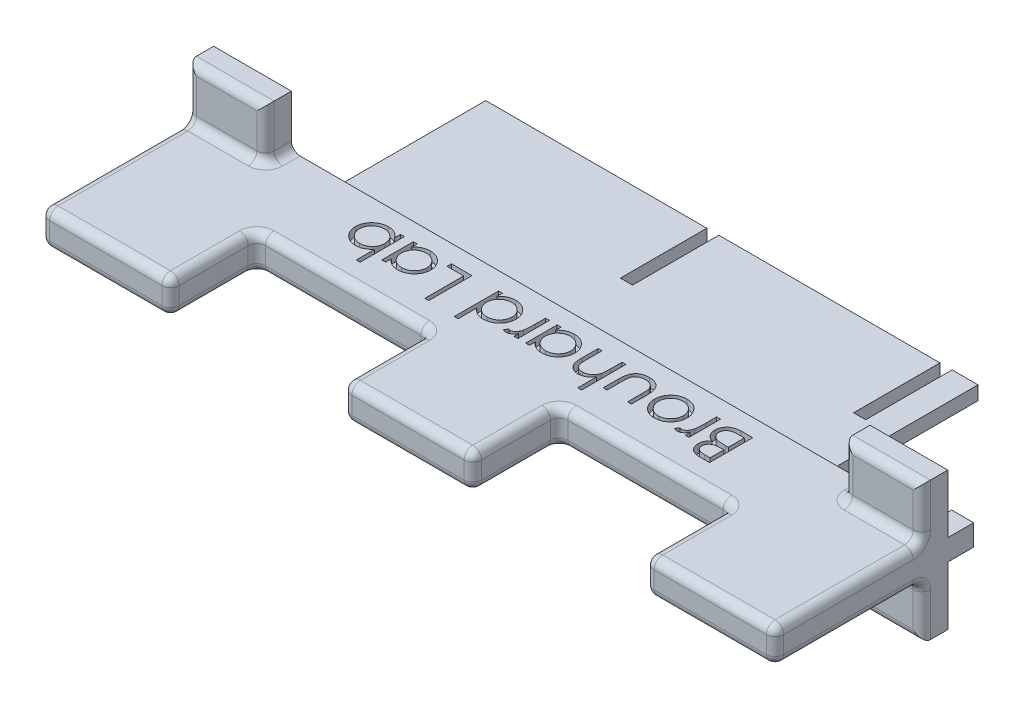
from build123d import *

# Parameters (mm, degrees)
SKETCH1_W           = 85
SKETCH1_H           = 4
BOSS_EXTRUDE1_DEPTH = 10
SKETCH2_W           = 15
SKETCH2_H           = 4
BOSS_EXTRUDE2_DEPTH = 10
SKETCH3_W           = 2.55
SKETCH3_H           = 2.45
BOSS_EXTRUDE3_DEPTH = 3
SKETCH4_W           = 57
SKETCH4_H           = 1.6
BOSS_EXTRUDE4_DEPTH = 7.5
SKETCH6_W           = 9
SKETCH6_H           = 6
BOSS_EXTRUDE6_DEPTH = 3
FILLET1_R           = 1
CUT_EXTRUDE1_DEPTH  = 1
SKETCH5_W           = 25.6
SKETCH5_H           = 1.6
SKETCH5_W_2         = 3
BOSS_EXTRUDE5_DEPTH = 10


with BuildPart() as part:
    # Sketch1 → Boss-Extrude1 (new body)
    with BuildSketch(Plane.XY):
        Rectangle(SKETCH1_W, SKETCH1_H)
    extrude(amount=BOSS_EXTRUDE1_DEPTH)

    # Sketch2 → Boss-Extrude2 (add)
    with BuildSketch(Plane.XY.offset(10)):
        with Locations((-35, 0)):
            Rectangle(SKETCH2_W, SKETCH2_H)
        with Locations((35, 0)):
            Rectangle(SKETCH2_W, SKETCH2_H)
        Rectangle(SKETCH2_W, SKETCH2_H)
    extrude(amount=BOSS_EXTRUDE2_DEPTH)

    # Sketch3 → Boss-Extrude3 (add)
    with BuildSketch(Plane(origin=(0, 0, 0), x_dir=(-1, 0, 0), z_dir=(0, 0, -1))):
        with Locations((-41.225, 0)):
            Rectangle(SKETCH3_W, SKETCH3_H)
        with Locations((41.225, 0)):
            Rectangle(SKETCH3_W, SKETCH3_H)
    extrude(amount=BOSS_EXTRUDE3_DEPTH)

    # Sketch4 → Boss-Extrude4 (add)
    with BuildSketch(Plane(origin=(0, 0, 0), x_dir=(-1, 0, 0), z_dir=(0, 0, -1))):
        Rectangle(SKETCH4_W, SKETCH4_H)
    extrude(amount=BOSS_EXTRUDE4_DEPTH)

    # Sketch6 → Boss-Extrude6 (add)
    with BuildSketch(Plane(origin=(0, 0, 0), x_dir=(-1, 0, 0), z_dir=(0, 0, -1))):
        with Locations((38, -5)):
            Rectangle(SKETCH6_W, SKETCH6_H)
        with Locations((38, 5)):
            Rectangle(SKETCH6_W, SKETCH6_H)
        with Locations((-38, -5)):
            Rectangle(SKETCH6_W, SKETCH6_H)
        with Locations((-38, 5)):
            Rectangle(SKETCH6_W, SKETCH6_H)
    extrude(amount=-BOSS_EXTRUDE6_DEPTH)

    # Fillet1
    fillet1_edges = [part.edges().sort_by_distance(p)[0] for p in [
        (-42.5, 5, 3),
        (-38, 2, 3),
        (-33.5, 5, 3),
        (-33.5, 2, 1.5),
        (-38, 8, 3),
        (42.5, -5, 3),
        (38, -2, 3),
        (33.5, -5, 3),
        (33.5, -2, 1.5),
        (38, -8, 3),
        (42.5, 5, 3),
        (38, 8, 3),
        (33.5, 5, 3),
        (38, 2, 3),
        (33.5, 2, 1.5),
        (-17.5, -2, 10),
        (-27.5, 0, 10),
        (-27.5, -2, 15),
        (-27.5, 2, 15),
        (-42.5, 0, 20),
        (-35, -2, 20),
        (-27.5, 0, 20),
        (-35, 2, 20),
        (17.5, 2, 10),
        (27.5, 0, 10),
        (27.5, 2, 15),
        (27.5, -2, 15),
        (42.5, 0, 20),
        (35, 2, 20),
        (27.5, 0, 20),
        (35, -2, 20),
        (17.5, -2, 10),
        (-17.5, 2, 10),
        (7.5, 0, 10),
        (7.5, -2, 15),
        (7.5, 2, 15),
        (-7.5, 0, 10),
        (-7.5, 2, 15),
        (-7.5, -2, 15),
        (7.5, 0, 20),
        (0, 2, 20),
        (-7.5, 0, 20),
        (0, -2, 20),
        (42.5, -2, 11.5),
        (-42.5, -2, 11.5),
        (-42.5, 2, 11.5),
        (42.5, 2, 11.5),
        (-42.5, -5, 3),
        (-38, -8, 3),
        (-33.5, -5, 3),
        (-38, -2, 3),
        (-33.5, -2, 1.5),
    ]]
    fillet(fillet1_edges, radius=FILLET1_R)

    # Sketch8 → Cut-Extrude1 (cut)
    with BuildSketch(Plane(origin=(0, 2, 0), x_dir=(1, 0, 0), z_dir=(0, 1, 0))):
        with BuildLine():
            Line((21.955128205, -7.045024133), (20.979567308, -7.045024133))
            add(Edge.make_bspline(
                [(20.979567308, -7.045024133), (20.931811586, -7.044777014), (20.839249111, -7.044298035), (20.704660144, -7.036696988), (20.578554958, -7.026592114), (20.461156398, -7.009641733), (20.351700568, -6.992066423), (20.251298675, -6.966270076), (20.159109728, -6.937777071), (20.048409672, -6.893936716), (19.92280529, -6.825852091), (19.787804083, -6.724876123), (19.670452795, -6.603814091), (19.570669416, -6.465854357), (19.490591132, -6.314083016), (19.43339094, -6.151765477), (19.396643358, -5.981632539), (19.392911608, -5.864990679), (19.391025641, -5.806041761)],
                knots=[0, 0, 0, 0, 0.000143243, 0.000277641, 0.000404323, 0.000522601, 0.000633422, 0.000736665, 0.000833282, 0.000922745, 0.001093491, 0.001260157, 0.001426607, 0.001597303, 0.001769346, 0.001939468, 0.002112331, 0.002288957, 0.002288957, 0.002288957, 0.002288957], degree=3))
            add(Edge.make_bspline(
                [(19.391025641, -5.806041761), (19.392566125, -5.750816773), (19.395593321, -5.642294463), (19.425166581, -5.484100137), (19.4698067, -5.333038737), (19.534225102, -5.190566035), (19.616363978, -5.057933935), (19.716298264, -4.937404803), (19.834792937, -4.831345021), (19.923759393, -4.772321243), (19.968950321, -4.742339838)],
                knots=[0, 0, 0, 0, 0.00016551, 0.000325243, 0.000481139, 0.000637145, 0.000792791, 0.000947835, 0.001105294, 0.001267844, 0.001267844, 0.001267844, 0.001267844], degree=3))
            add(Edge.make_bspline(
                [(19.968950321, -4.742339838), (19.912145679, -4.720542475), (19.803464327, -4.678838718), (19.653711211, -4.604821394), (19.524645211, -4.524933301), (19.41460302, -4.438588883), (19.32239544, -4.34296875), (19.240253224, -4.240591123), (19.170541651, -4.127890536), (19.111062126, -4.007309158), (19.063944891, -3.879485542), (19.031238978, -3.745375962), (19.010496783, -3.606499394), (19.007784363, -3.512111636), (19.006410256, -3.464294967)],
                knots=[0, 0, 0, 0, 0.000182459, 0.00034909, 0.000500276, 0.000637148, 0.000767471, 0.00089793, 0.001030217, 0.001164151, 0.001300726, 0.001437979, 0.001577644, 0.001721044, 0.001721044, 0.001721044, 0.001721044], degree=3))
            add(Edge.make_bspline(
                [(19.006410256, -3.464294967), (19.007805885, -3.41548523), (19.010551822, -3.319450707), (19.030807012, -3.178370784), (19.065112767, -3.043553694), (19.112331393, -2.914102037), (19.173883248, -2.790773975), (19.248244287, -2.672600284), (19.337493216, -2.561332318), (19.437996289, -2.45535544), (19.550128803, -2.358444164), (19.673690061, -2.2751618), (19.805513315, -2.203227398), (19.947403728, -2.145396174), (20.098354491, -2.100124903), (20.258400966, -2.068824422), (20.427452272, -2.047649449), (20.543467886, -2.045914087), (20.602964744, -2.045024133)],
                knots=[0, 0, 0, 0, 0.000146402, 0.00028805, 0.000426518, 0.000563092, 0.000700608, 0.000839267, 0.000981145, 0.001127794, 0.001276955, 0.001424748, 0.00157399, 0.001726698, 0.001883553, 0.002046002, 0.002215459, 0.002393845, 0.002393845, 0.002393845, 0.002393845], degree=3))
            Line((20.602964744, -2.045024133), (21.955128205, -2.045024133))
            Line((21.955128205, -2.045024133), (21.955128205, -7.045024133))
        make_face()
        with BuildLine():
            Line((21.506410256, -6.53220362), (21.506410256, -4.929639518))
            Line((21.506410256, -4.929639518), (21.204927885, -4.929639518))
            add(Edge.make_bspline(
                [(21.204927885, -4.929639518), (21.16085778, -4.930206082), (21.075705357, -4.9313008), (20.952063514, -4.934535484), (20.837581625, -4.943196106), (20.731865233, -4.952356158), (20.635622811, -4.966460704), (20.548532434, -4.983720889), (20.469810894, -5.00181496), (20.379071632, -5.032675643), (20.276157749, -5.077807077), (20.16721677, -5.149562501), (20.069164992, -5.232639769), (19.988277934, -5.331182392), (19.920936523, -5.437599512), (19.875598165, -5.552684686), (19.843986577, -5.672472047), (19.841172407, -5.755083607), (19.83974359, -5.797027338)],
                knots=[0, 0, 0, 0, 0.000132227, 0.000255489, 0.000370952, 0.000476596, 0.000573767, 0.000662554, 0.000742964, 0.000815812, 0.000949851, 0.001078759, 0.001205868, 0.001333854, 0.001459773, 0.001581973, 0.001703679, 0.001829203, 0.001829203, 0.001829203, 0.001829203], degree=3))
            add(Edge.make_bspline(
                [(19.83974359, -5.797027338), (19.840440447, -5.824795004), (19.841807408, -5.879264312), (19.85469429, -5.958622966), (19.872478035, -6.034141042), (19.901807859, -6.103782707), (19.936556119, -6.169993364), (19.98109509, -6.230681546), (20.03245262, -6.287491301), (20.092329064, -6.338899898), (20.160479658, -6.385396007), (20.239063252, -6.424101797), (20.325943351, -6.458499162), (20.422931675, -6.48457317), (20.528096305, -6.507209559), (20.643041681, -6.521483941), (20.767075062, -6.530654029), (20.853013063, -6.531675569), (20.897435897, -6.53220362)],
                knots=[0, 0, 0, 0, 8.3229e-05, 0.000163264, 0.000240757, 0.000315341, 0.000389283, 0.000464617, 0.000540481, 0.000618594, 0.000700823, 0.000787274, 0.000880832, 0.000980716, 0.001088168, 0.001203335, 0.00132786, 0.001461107, 0.001461107, 0.001461107, 0.001461107], degree=3))
            Line((20.897435897, -6.53220362), (21.506410256, -6.53220362))
        make_face(mode=Mode.SUBTRACT)
        with BuildLine():
            Line((21.506410256, -4.416819005), (21.506410256, -2.557844646))
            Line((21.506410256, -2.557844646), (20.867387821, -2.557844646))
            add(Edge.make_bspline(
                [(20.867387821, -2.557844646), (20.82165107, -2.558445571), (20.733499514, -2.559603775), (20.606126985, -2.562352033), (20.48869926, -2.57254806), (20.380238634, -2.582323383), (20.281246941, -2.598293401), (20.190761319, -2.61375789), (20.110848501, -2.63651465), (20.017345889, -2.667828353), (19.912764158, -2.717871803), (19.798555972, -2.791464981), (19.697962318, -2.881106895), (19.612615651, -2.984324471), (19.541653639, -3.095395221), (19.492561941, -3.214537751), (19.460753316, -3.337772506), (19.457007017, -3.422035912), (19.455128205, -3.464294967)],
                knots=[0, 0, 0, 0, 0.000137234, 0.000264501, 0.000382034, 0.000490767, 0.000591058, 0.000682796, 0.000765899, 0.000840017, 0.000978463, 0.001112367, 0.001246451, 0.001380849, 0.001513136, 0.001640186, 0.001766022, 0.001892621, 0.001892621, 0.001892621, 0.001892621], degree=3))
            add(Edge.make_bspline(
                [(19.455128205, -3.464294967), (19.455511728, -3.490717987), (19.456272588, -3.543137822), (19.468232548, -3.620102651), (19.484829912, -3.695025725), (19.509289766, -3.766889341), (19.538879538, -3.836930979), (19.577915987, -3.902871611), (19.621948812, -3.967518228), (19.690148998, -4.050208407), (19.790699472, -4.144331407), (19.933635519, -4.235332182), (20.095250073, -4.309910154), (20.212743455, -4.341437989), (20.2734375, -4.357724454)],
                knots=[0, 0, 0, 0, 7.9184e-05, 0.00015709, 0.000233139, 0.000309156, 0.000384516, 0.000460796, 0.000538586, 0.000618995, 0.000781989, 0.000949233, 0.001125381, 0.001313608, 0.001313608, 0.001313608, 0.001313608], degree=3))
            add(Edge.make_bspline(
                [(20.2734375, -4.357724454), (20.297764757, -4.36266062), (20.350511268, -4.373363246), (20.436522534, -4.384653585), (20.535045896, -4.394781387), (20.645660247, -4.402076233), (20.768805516, -4.409907124), (20.904442139, -4.412844185), (21.052666008, -4.416429024), (21.15551238, -4.416685686), (21.208934295, -4.416819005)],
                knots=[0, 0, 0, 0, 7.4449e-05, 0.000161422, 0.000260089, 0.000371555, 0.000493951, 0.000630228, 0.000778496, 0.000938755, 0.000938755, 0.000938755, 0.000938755], degree=3))
            Line((21.208934295, -4.416819005), (21.506410256, -4.416819005))
        make_face(mode=Mode.SUBTRACT)
        with BuildLine():
            Line((18.237179487, -5.698870287), (17.788461538, -5.698870287))
            Line((17.788461538, -5.698870287), (17.788461538, -5.16100971))
            add(Edge.make_bspline(
                [(17.788461538, -5.16100971), (17.755359908, -5.211117117), (17.692053298, -5.306947144), (17.586273377, -5.43343718), (17.479111393, -5.53983342), (17.366921794, -5.622588498), (17.252557594, -5.685650706), (17.136357118, -5.730343447), (17.017481778, -5.757585182), (16.937237879, -5.761174556), (16.897035256, -5.762972851)],
                knots=[0, 0, 0, 0, 0.000180032, 0.00034431, 0.000493764, 0.000631989, 0.000761087, 0.000884414, 0.00100446, 0.00112499, 0.00112499, 0.00112499, 0.00112499], degree=3))
            add(Edge.make_bspline(
                [(16.897035256, -5.762972851), (16.865844687, -5.761310147), (16.801992924, -5.757906343), (16.705041331, -5.732794344), (16.604739598, -5.694222955), (16.540012887, -5.657063647), (16.506410256, -5.637772531)],
                knots=[0, 0, 0, 0, 9.3493e-05, 0.000191394, 0.000298902, 0.000414971, 0.000414971, 0.000414971, 0.000414971], degree=3))
            Line((16.506410256, -5.637772531), (16.752804487, -5.249150736))
            add(Edge.make_bspline(
                [(16.752804487, -5.249150736), (16.774388803, -5.258779687), (16.815359967, -5.277057281), (16.875295061, -5.298688724), (16.930554114, -5.311425747), (16.965759197, -5.313355343), (16.982171474, -5.314254902)],
                knots=[0, 0, 0, 0, 7.0888e-05, 0.000134558, 0.000190943, 0.000240184, 0.000240184, 0.000240184, 0.000240184], degree=3))
            add(Edge.make_bspline(
                [(16.982171474, -5.314254902), (17.018552318, -5.311962095), (17.092095887, -5.307327204), (17.199553418, -5.267726819), (17.305221395, -5.20820996), (17.387285817, -5.138004944), (17.451536641, -5.071852679), (17.497773588, -5.013639038), (17.539299542, -4.947803919), (17.579572406, -4.876841023), (17.616991286, -4.798984205), (17.65042989, -4.714102186), (17.681701622, -4.622897124), (17.699312387, -4.559480067), (17.708333333, -4.526995287)],
                knots=[0, 0, 0, 0, 0.000108839, 0.000220017, 0.000339778, 0.000471355, 0.000542193, 0.000616339, 0.000693851, 0.000775474, 0.000861039, 0.000952734, 0.001049023, 0.001150145, 0.001150145, 0.001150145, 0.001150145], degree=3))
            add(Edge.make_bspline(
                [(17.708333333, -4.526995287), (17.715105579, -4.4980295), (17.73018081, -4.433550753), (17.744447085, -4.325868753), (17.75911049, -4.198727857), (17.769124119, -4.051980366), (17.778583328, -3.885062178), (17.783808984, -3.698693379), (17.788295276, -3.492361731), (17.78840435, -3.348446216), (17.788461538, -3.272988877)],
                knots=[0, 0, 0, 0, 8.9193e-05, 0.000198547, 0.000325526, 0.000473173, 0.000639683, 0.000827079, 0.001032447, 0.001258811, 0.001258811, 0.001258811, 0.001258811], degree=3))
            Line((17.788461538, -3.272988877), (17.788461538, -2.045024133))
            Line((17.788461538, -2.045024133), (18.237179487, -2.045024133))
            Line((18.237179487, -2.045024133), (18.237179487, -5.698870287))
        make_face()
        with BuildLine():
            add(Edge.make_bspline(
                [(14.29286859, -5.762972851), (14.224307927, -5.761517291), (14.089877222, -5.758663293), (13.893032913, -5.728009819), (13.705327588, -5.681525783), (13.525956048, -5.616093456), (13.356402056, -5.530243686), (13.195151776, -5.426425769), (13.042528278, -5.303937317), (12.951070622, -5.209132095), (12.904647436, -5.16100971)],
                knots=[0, 0, 0, 0, 0.000205526, 0.000402987, 0.000596112, 0.000784972, 0.000974447, 0.001165038, 0.001359476, 0.001559909, 0.001559909, 0.001559909, 0.001559909], degree=3))
            add(Edge.make_bspline(
                [(12.904647436, -5.16100971), (12.864673216, -5.11498973), (12.785498387, -5.023840384), (12.683975931, -4.876046652), (12.59651656, -4.722989365), (12.526426616, -4.562636041), (12.471162296, -4.396386511), (12.431925587, -4.223669352), (12.408587109, -4.044865999), (12.405440013, -3.923431945), (12.403846154, -3.861931185)],
                knots=[0, 0, 0, 0, 0.000182745, 0.000361954, 0.000536876, 0.000710881, 0.000886036, 0.001061708, 0.001241475, 0.001425944, 0.001425944, 0.001425944, 0.001425944], degree=3))
            add(Edge.make_bspline(
                [(12.403846154, -3.861931185), (12.405248064, -3.800073959), (12.408018305, -3.677841197), (12.434223472, -3.497813533), (12.474982163, -3.323249495), (12.533313369, -3.154879952), (12.608110636, -2.992190127), (12.699383171, -2.835891045), (12.807770716, -2.685672654), (12.930635425, -2.542816985), (13.066416897, -2.411135675), (13.21375075, -2.296436369), (13.369848434, -2.197755629), (13.536840837, -2.119375683), (13.712350874, -2.056195988), (13.8974949, -2.012629522), (14.09210775, -1.986052796), (14.225006973, -1.982656037), (14.29286859, -1.980921569)],
                knots=[0, 0, 0, 0, 0.00018547, 0.000366497, 0.000544574, 0.000722589, 0.000900065, 0.001080956, 0.001264689, 0.001455025, 0.001645575, 0.001831106, 0.002014249, 0.002198383, 0.002383395, 0.002572886, 0.002767942, 0.002971467, 0.002971467, 0.002971467, 0.002971467], degree=3))
            add(Edge.make_bspline(
                [(14.29286859, -1.980921569), (14.361059424, -1.982670388), (14.494614618, -1.986095539), (14.689960267, -2.012431829), (14.875883807, -2.056661478), (15.052224048, -2.118593533), (15.219215773, -2.198399418), (15.37588985, -2.296052412), (15.523293198, -2.411193757), (15.65911724, -2.542801247), (15.781970535, -2.685676709), (15.890361026, -2.835889993), (15.981632796, -2.992190401), (16.056430263, -3.154879879), (16.114761415, -3.323249515), (16.155520121, -3.497813528), (16.181725284, -3.677841198), (16.184495525, -3.80007396), (16.185897436, -3.861931185)],
                knots=[0, 0, 0, 0, 0.000204526, 0.000400574, 0.000590065, 0.000776965, 0.000960195, 0.001144188, 0.00132972, 0.001520269, 0.001710605, 0.001894339, 0.00207523, 0.002252706, 0.002430721, 0.002608798, 0.002789825, 0.002975294, 0.002975294, 0.002975294, 0.002975294], degree=3))
            add(Edge.make_bspline(
                [(16.185897436, -3.861931185), (16.184296519, -3.923099043), (16.18112698, -4.044200892), (16.157756652, -4.22264832), (16.118946868, -4.394836864), (16.062916427, -4.560178538), (15.992956591, -4.720146456), (15.90637746, -4.873764934), (15.803872945, -5.02091287), (15.725005709, -5.111941341), (15.685096154, -5.158004902)],
                knots=[0, 0, 0, 0, 0.000183468, 0.000363236, 0.000538908, 0.000712162, 0.000886167, 0.001061962, 0.001240348, 0.001423094, 0.001423094, 0.001423094, 0.001423094], degree=3))
            add(Edge.make_bspline(
                [(15.685096154, -5.158004902), (15.638739114, -5.20653651), (15.547569839, -5.301982456), (15.394241809, -5.424229232), (15.233685171, -5.529446865), (15.063037498, -5.615253429), (14.883167202, -5.681407061), (14.694066814, -5.728226774), (14.496506031, -5.758527704), (14.361424213, -5.761476369), (14.29286859, -5.762972851)],
                knots=[0, 0, 0, 0, 0.00020114, 0.000395577, 0.000586713, 0.000776188, 0.000967274, 0.001160399, 0.001359841, 0.001565367, 0.001565367, 0.001565367, 0.001565367], degree=3))
        make_face()
        with BuildLine():
            add(Edge.make_bspline(
                [(14.294871795, -5.314254902), (14.343354042, -5.31287684), (14.439066976, -5.310156289), (14.579952881, -5.289466071), (14.715578773, -5.256679949), (14.84621924, -5.210117374), (14.971369132, -5.149920796), (15.091165691, -5.076401027), (15.205288814, -4.989167289), (15.312855022, -4.88995037), (15.412753003, -4.782192755), (15.499001382, -4.666286529), (15.572889716, -4.545452386), (15.633262525, -4.419007361), (15.679580189, -4.286604065), (15.712397714, -4.149000046), (15.733127199, -4.005785755), (15.735814091, -3.908409845), (15.737179487, -3.858926377)],
                knots=[0, 0, 0, 0, 0.000145402, 0.00028705, 0.000426247, 0.000563423, 0.000702299, 0.000842129, 0.000984361, 0.00113252, 0.001280679, 0.00142451, 0.001565195, 0.001704975, 0.001844039, 0.001985183, 0.002128814, 0.002277217, 0.002277217, 0.002277217, 0.002277217], degree=3))
            add(Edge.make_bspline(
                [(15.737179487, -3.858926377), (15.734890082, -3.794992084), (15.730346041, -3.668094469), (15.693206633, -3.48126298), (15.631516344, -3.301562306), (15.546449569, -3.131156088), (15.441687276, -2.973216762), (15.31918926, -2.831196974), (15.177261944, -2.710573578), (15.020738225, -2.609127271), (14.851836243, -2.5292384), (14.673387712, -2.471947456), (14.487017459, -2.435206285), (14.359480893, -2.431511347), (14.294871795, -2.429639518)],
                knots=[0, 0, 0, 0, 0.000191683, 0.000380455, 0.000568919, 0.000760186, 0.000950198, 0.001136194, 0.00132088, 0.001507019, 0.001694298, 0.001879594, 0.002068178, 0.002261801, 0.002261801, 0.002261801, 0.002261801], degree=3))
            add(Edge.make_bspline(
                [(14.294871795, -2.429639518), (14.23025898, -2.431500504), (14.102715078, -2.435174039), (13.916085515, -2.472133599), (13.737147914, -2.528989279), (13.568070317, -2.609217501), (13.411475317, -2.710190138), (13.270561459, -2.831884154), (13.147008507, -2.972843418), (13.04214248, -3.130946672), (12.958446366, -3.301827223), (12.896465966, -3.481229869), (12.859415628, -3.668102902), (12.854859565, -3.794994909), (12.852564103, -3.858926377)],
                knots=[0, 0, 0, 0, 0.000193623, 0.000382206, 0.000568456, 0.000755734, 0.000941873, 0.001125801, 0.001312456, 0.001502468, 0.001693291, 0.001881755, 0.002070527, 0.00226221, 0.00226221, 0.00226221, 0.00226221], degree=3))
            add(Edge.make_bspline(
                [(12.852564103, -3.858926377), (12.85391927, -3.908413822), (12.856586033, -4.00579756), (12.877461924, -4.148954918), (12.909764333, -4.286878115), (12.958078967, -4.418473367), (13.016348399, -4.546067931), (13.092028067, -4.665924648), (13.177874936, -4.782266279), (13.277956043, -4.889885455), (13.385510177, -4.98952979), (13.500490643, -5.076083255), (13.620342842, -5.149962779), (13.745532283, -5.210124787), (13.875877117, -5.256500729), (14.011091241, -5.289608892), (14.151353237, -5.310080851), (14.246726302, -5.312854653), (14.294871795, -5.314254902)],
                knots=[0, 0, 0, 0, 0.000148403, 0.000292034, 0.000433178, 0.000572578, 0.00071193, 0.000853138, 0.000996969, 0.001145128, 0.001293287, 0.001436317, 0.001576147, 0.001715023, 0.001852199, 0.001990424, 0.002132072, 0.002276473, 0.002276473, 0.002276473, 0.002276473], degree=3))
        make_face(mode=Mode.SUBTRACT)
        with BuildLine():
            Line((11.570512821, -5.698870287), (11.121794872, -5.698870287))
            Line((11.121794872, -5.698870287), (11.121794872, -4.004158749))
            add(Edge.make_bspline(
                [(11.121794872, -4.004158749), (11.121592151, -3.954411964), (11.121204354, -3.859248695), (11.118574439, -3.722312714), (11.112388591, -3.597431696), (11.104654555, -3.484533501), (11.094708647, -3.383637227), (11.082875275, -3.295095289), (11.069648958, -3.217903597), (11.056702224, -3.171413089), (11.05068109, -3.149791761)],
                knots=[0, 0, 0, 0, 0.000149242, 0.000285493, 0.000410838, 0.000524302, 0.000624962, 0.000714911, 0.000792314, 0.000859608, 0.000859608, 0.000859608, 0.000859608], degree=3))
            add(Edge.make_bspline(
                [(11.05068109, -3.149791761), (11.041021805, -3.122616307), (11.02190405, -3.06883037), (10.987228565, -2.991130691), (10.944327515, -2.919170094), (10.897397624, -2.850149082), (10.843207537, -2.786203671), (10.78254961, -2.72691621), (10.716500508, -2.671595092), (10.619751651, -2.6048734), (10.487494763, -2.534263345), (10.314242396, -2.472488378), (10.126045943, -2.436112097), (9.995820794, -2.431836921), (9.928886218, -2.429639518)],
                knots=[0, 0, 0, 0, 8.6516e-05, 0.000171232, 0.000254721, 0.000337515, 0.000421387, 0.00050567, 0.000591721, 0.00067952, 0.000857864, 0.001039709, 0.001229465, 0.001430146, 0.001430146, 0.001430146, 0.001430146], degree=3))
            add(Edge.make_bspline(
                [(9.928886218, -2.429639518), (9.86194316, -2.431828713), (9.732748927, -2.436053669), (9.546518851, -2.471939165), (9.375968682, -2.530483395), (9.223089747, -2.613350563), (9.088841758, -2.714376404), (8.976981124, -2.832969142), (8.884684323, -2.965323174), (8.844385248, -3.064072442), (8.82411859, -3.113734069)],
                knots=[0, 0, 0, 0, 0.000200681, 0.000387296, 0.000566586, 0.000739571, 0.000906841, 0.001068376, 0.001227003, 0.001387484, 0.001387484, 0.001387484, 0.001387484], degree=3))
            add(Edge.make_bspline(
                [(8.82411859, -3.113734069), (8.8181224, -3.1336855), (8.80486629, -3.177793242), (8.790725551, -3.252630176), (8.777460105, -3.341789135), (8.768616165, -3.446206446), (8.758522511, -3.564961319), (8.755037146, -3.698667884), (8.750059864, -3.846538026), (8.750020544, -3.950065981), (8.75, -4.004158749)],
                knots=[0, 0, 0, 0, 6.2462e-05, 0.000138088, 0.000228176, 0.000332823, 0.000452355, 0.000585662, 0.000733953, 0.000896216, 0.000896216, 0.000896216, 0.000896216], degree=3))
            Line((8.75, -4.004158749), (8.75, -5.698870287))
            Line((8.75, -5.698870287), (8.301282051, -5.698870287))
            Line((8.301282051, -5.698870287), (8.301282051, -3.920024133))
            add(Edge.make_bspline(
                [(8.301282051, -3.920024133), (8.30191531, -3.859585653), (8.303143917, -3.742326733), (8.310980731, -3.571916291), (8.324614367, -3.412799073), (8.344773775, -3.265462167), (8.369229918, -3.129870336), (8.400154934, -3.00598092), (8.437277048, -2.893621613), (8.479165629, -2.791153018), (8.528529202, -2.698158121), (8.581390514, -2.610389295), (8.640827886, -2.528135886), (8.705652894, -2.450645369), (8.777741804, -2.379798189), (8.85333008, -2.311961845), (8.93610888, -2.251321381), (9.023288539, -2.194646502), (9.117066908, -2.144351467), (9.216637391, -2.100832577), (9.321894658, -2.063022013), (9.433003103, -2.033803946), (9.549897573, -2.009153726), (9.67242881, -1.992746928), (9.800829998, -1.982271357), (9.888132562, -1.981379054), (9.932892628, -1.980921569)],
                knots=[0, 0, 0, 0, 0.000181315, 0.000351776, 0.000511647, 0.000660239, 0.000797754, 0.000924804, 0.001042946, 0.001152506, 0.001256441, 0.001358477, 0.001459659, 0.001560587, 0.001661157, 0.001762636, 0.001865001, 0.001968632, 0.00207439, 0.002183817, 0.002294379, 0.002409546, 0.002528193, 0.002652561, 0.002780158, 0.002914407, 0.002914407, 0.002914407, 0.002914407], degree=3))
            add(Edge.make_bspline(
                [(9.932892628, -1.980921569), (9.977316456, -1.981406186), (10.064613414, -1.982358504), (10.192711845, -1.992570693), (10.315507575, -2.00940504), (10.432494069, -2.033606354), (10.544142851, -2.063257518), (10.649911875, -2.100566743), (10.749934706, -2.144600485), (10.84442655, -2.194693497), (10.933073912, -2.251115088), (11.015677547, -2.313213364), (11.093710062, -2.379368112), (11.165005381, -2.451835522), (11.23008642, -2.530073038), (11.28923533, -2.613729086), (11.343463789, -2.701858176), (11.392537938, -2.79623559), (11.434697953, -2.899909467), (11.471919623, -3.014619732), (11.502363426, -3.141623289), (11.527138371, -3.28081177), (11.547069003, -3.431518969), (11.560906348, -3.594616706), (11.568643249, -3.769707694), (11.569876194, -3.890636109), (11.570512821, -3.953077018)],
                knots=[0, 0, 0, 0, 0.000133247, 0.000261843, 0.000385219, 0.000504847, 0.000620013, 0.00073152, 0.000840947, 0.000947589, 0.001052063, 0.001155829, 0.001257407, 0.001358687, 0.001460383, 0.00156238, 0.001665793, 0.001770617, 0.001881102, 0.002001148, 0.002132087, 0.002272558, 0.00242512, 0.002587985, 0.002763448, 0.002950772, 0.002950772, 0.002950772, 0.002950772], degree=3))
            Line((11.570512821, -3.953077018), (11.570512821, -5.698870287))
        make_face()
        with BuildLine():
            Line((7.275641026, -7.173229261), (6.826923077, -7.173229261))
            Line((6.826923077, -7.173229261), (6.826923077, -5.00876612))
            add(Edge.make_bspline(
                [(6.826923077, -5.00876612), (6.778678808, -5.068888094), (6.684893793, -5.185762911), (6.528113976, -5.339904506), (6.36474826, -5.471196487), (6.193410264, -5.578408978), (6.014828183, -5.661579829), (5.828563194, -5.719766634), (5.635090167, -5.756050633), (5.503296595, -5.760649137), (5.436698718, -5.762972851)],
                knots=[0, 0, 0, 0, 0.000231093, 0.000449235, 0.000658061, 0.000858722, 0.001054107, 0.001247341, 0.001442817, 0.001642498, 0.001642498, 0.001642498, 0.001642498], degree=3))
            add(Edge.make_bspline(
                [(5.436698718, -5.762972851), (5.369051259, -5.760620551), (5.236582495, -5.756014225), (5.044402774, -5.715426657), (4.863656734, -5.651196128), (4.696758785, -5.560924861), (4.546286047, -5.448841659), (4.415775284, -5.31738737), (4.306291209, -5.168293369), (4.233038251, -5.029320354), (4.185028125, -4.905733149), (4.154679673, -4.799671692), (4.128934509, -4.68150037), (4.106507375, -4.551264166), (4.091559078, -4.408342759), (4.079552578, -4.253379458), (4.071014758, -4.086383599), (4.070683898, -3.970783239), (4.070512821, -3.91100971)],
                knots=[0, 0, 0, 0, 0.000202742, 0.000397014, 0.000586474, 0.000776485, 0.000963986, 0.001147421, 0.001330122, 0.001516953, 0.001616837, 0.001727454, 0.0018475, 0.00197956, 0.002123683, 0.002278397, 0.002445857, 0.002625155, 0.002625155, 0.002625155, 0.002625155], degree=3))
            Line((4.070512821, -3.91100971), (4.070512821, -2.045024133))
            Line((4.070512821, -2.045024133), (4.519230769, -2.045024133))
            Line((4.519230769, -2.045024133), (4.519230769, -3.763774133))
            add(Edge.make_bspline(
                [(4.519230769, -3.763774133), (4.519501544, -3.813520868), (4.52001949, -3.908677905), (4.521752659, -4.044914373), (4.525533642, -4.16814974), (4.531869413, -4.278639822), (4.53824468, -4.376234881), (4.547283145, -4.46109433), (4.557720701, -4.532685817), (4.567105279, -4.575778103), (4.571314103, -4.595104261)],
                knots=[0, 0, 0, 0, 0.000149242, 0.000285475, 0.000408737, 0.000519077, 0.000617484, 0.0007021, 0.000775053, 0.000834376, 0.000834376, 0.000834376, 0.000834376], degree=3))
            add(Edge.make_bspline(
                [(4.571314103, -4.595104261), (4.587558684, -4.651851981), (4.618706291, -4.760660919), (4.692549434, -4.908198617), (4.782632802, -5.035130852), (4.894290172, -5.137852366), (5.023812243, -5.21879062), (5.172428658, -5.273933897), (5.338240367, -5.309099366), (5.454866892, -5.312485195), (5.515825321, -5.314254902)],
                knots=[0, 0, 0, 0, 0.000176748, 0.000338899, 0.000492364, 0.000641202, 0.000791008, 0.00094763, 0.001114405, 0.001297029, 0.001297029, 0.001297029, 0.001297029], degree=3))
            add(Edge.make_bspline(
                [(5.515825321, -5.314254902), (5.551925349, -5.313584935), (5.623366372, -5.312259087), (5.729246241, -5.298610846), (5.8322736, -5.277055291), (5.932171925, -5.245215815), (6.029144995, -5.206505033), (6.123586995, -5.15899916), (6.21420543, -5.101559446), (6.302169918, -5.036911618), (6.384056208, -4.965394032), (6.460236741, -4.889895628), (6.528148933, -4.809503542), (6.589675418, -4.725503187), (6.642787274, -4.636743532), (6.689148815, -4.544080206), (6.728485525, -4.44739143), (6.748032228, -4.380284199), (6.7578125, -4.346706826)],
                knots=[0, 0, 0, 0, 0.000108247, 0.000214218, 0.000319711, 0.000423617, 0.000528331, 0.0006327, 0.00074025, 0.000849828, 0.000959881, 0.001066117, 0.001171281, 0.001275259, 0.001378152, 0.001481176, 0.00158589, 0.001690753, 0.001690753, 0.001690753, 0.001690753], degree=3))
            add(Edge.make_bspline(
                [(6.7578125, -4.346706826), (6.763440253, -4.322391181), (6.77570382, -4.2694044), (6.789010725, -4.182012509), (6.800921863, -4.080460549), (6.81099122, -3.964902548), (6.817167057, -3.834915059), (6.823821687, -3.691385118), (6.82629885, -3.533413659), (6.826708783, -3.423562934), (6.826923077, -3.366137915)],
                knots=[0, 0, 0, 0, 7.4853e-05, 0.000163113, 0.000264986, 0.000381603, 0.000511, 0.000655356, 0.000812636, 0.000984915, 0.000984915, 0.000984915, 0.000984915], degree=3))
            Line((6.826923077, -3.366137915), (6.826923077, -2.045024133))
            Line((6.826923077, -2.045024133), (7.275641026, -2.045024133))
            Line((7.275641026, -2.045024133), (7.275641026, -7.173229261))
        make_face()
        with BuildLine():
            Line((-0.673076923, -5.698870287), (-0.673076923, -2.045024133))
            Line((-0.673076923, -2.045024133), (-0.224358974, -2.045024133))
            Line((-0.224358974, -2.045024133), (-0.224358974, -2.677035351))
            add(Edge.make_bspline(
                [(-0.224358974, -2.677035351), (-0.173692153, -2.619914798), (-0.074668173, -2.508277549), (0.089136249, -2.361533046), (0.264203306, -2.241723382), (0.447550404, -2.144473643), (0.640596711, -2.07116495), (0.842208477, -2.019519884), (1.052227954, -1.985924035), (1.195449856, -1.982604018), (1.268028846, -1.980921569)],
                knots=[0, 0, 0, 0, 0.000228947, 0.000447457, 0.00065777, 0.000863866, 0.001068669, 0.001275649, 0.001487424, 0.001705002, 0.001705002, 0.001705002, 0.001705002], degree=3))
            add(Edge.make_bspline(
                [(1.268028846, -1.980921569), (1.33255467, -1.982673239), (1.459802451, -1.986127609), (1.646984326, -2.01293508), (1.827125421, -2.055963389), (2.000340544, -2.115878617), (2.16545602, -2.194944018), (2.323402232, -2.290624075), (2.474547798, -2.403447762), (2.616018245, -2.532931528), (2.746457503, -2.673420564), (2.860578679, -2.823701191), (2.957300092, -2.98170931), (3.03678777, -3.14740051), (3.098299504, -3.320653672), (3.141095026, -3.50134994), (3.16787361, -3.689188645), (3.17132623, -3.817102795), (3.173076923, -3.881963236)],
                knots=[0, 0, 0, 0, 0.000193519, 0.000381629, 0.000566016, 0.000748473, 0.000930368, 0.001114167, 0.001301667, 0.001495236, 0.001688742, 0.001876044, 0.002060364, 0.002243594, 0.002426383, 0.002610771, 0.002799872, 0.002994392, 0.002994392, 0.002994392, 0.002994392], degree=3))
            add(Edge.make_bspline(
                [(3.173076923, -3.881963236), (3.1712874, -3.945483083), (3.167749609, -4.071058395), (3.141381566, -4.255738336), (3.097074815, -4.43363601), (3.034777431, -4.604092418), (2.955247483, -4.767794043), (2.856862681, -4.923460082), (2.742782629, -5.073471787), (2.610949305, -5.213018547), (2.468209109, -5.341451795), (2.316217898, -5.454549666), (2.156870853, -5.549984408), (1.989848458, -5.627563574), (1.81633338, -5.689212702), (1.635007518, -5.732188081), (1.446695469, -5.757450724), (1.318853253, -5.761114455), (1.25400641, -5.762972851)],
                knots=[0, 0, 0, 0, 0.000190518, 0.000376644, 0.000558351, 0.000739594, 0.000920119, 0.001103261, 0.001291171, 0.001484625, 0.001678266, 0.00186657, 0.002052086, 0.00223446, 0.002418194, 0.002603555, 0.002792521, 0.002987041, 0.002987041, 0.002987041, 0.002987041], degree=3))
            add(Edge.make_bspline(
                [(1.25400641, -5.762972851), (1.179433695, -5.760926632), (1.03320012, -5.756914093), (0.81900525, -5.723236763), (0.616281151, -5.666868078), (0.423271915, -5.589930632), (0.242689948, -5.486323272), (0.072799241, -5.358126181), (-0.084384391, -5.202231444), (-0.176893656, -5.083637559), (-0.224358974, -5.022788556)],
                knots=[0, 0, 0, 0, 0.000223629, 0.000438526, 0.00064848, 0.000853819, 0.001060171, 0.00127111, 0.001490669, 0.00172203, 0.00172203, 0.00172203, 0.00172203], degree=3))
            Line((-0.224358974, -5.022788556), (-0.224358974, -5.698870287))
            Line((-0.224358974, -5.698870287), (-0.673076923, -5.698870287))
        make_face()
        with BuildLine():
            add(Edge.make_bspline(
                [(1.247996795, -5.314254902), (1.313587334, -5.311919162), (1.443052626, -5.307308782), (1.633135329, -5.271375167), (1.81493707, -5.211432861), (1.988162207, -5.129927244), (2.148028307, -5.025521063), (2.293274093, -4.90241808), (2.4199622, -4.759110049), (2.527080559, -4.598889493), (2.61600865, -4.428155027), (2.677375939, -4.248376808), (2.71813637, -4.064413876), (2.722279372, -3.93960414), (2.724358974, -3.876955223)],
                knots=[0, 0, 0, 0, 0.000196682, 0.000388218, 0.000577945, 0.000769701, 0.000960837, 0.001149109, 0.001339255, 0.001532603, 0.001726118, 0.001914908, 0.002101131, 0.002288816, 0.002288816, 0.002288816, 0.002288816], degree=3))
            add(Edge.make_bspline(
                [(2.724358974, -3.876955223), (2.721659394, -3.814696014), (2.716270816, -3.690421632), (2.678628159, -3.506176784), (2.612554386, -3.327571475), (2.52557156, -3.154636161), (2.41676702, -2.993220534), (2.290328958, -2.847266396), (2.144346166, -2.722265786), (1.983072348, -2.617564507), (1.811006067, -2.533340742), (1.629993631, -2.473937453), (1.443190032, -2.436430737), (1.315946515, -2.431910872), (1.252003205, -2.429639518)],
                knots=[0, 0, 0, 0, 0.000186753, 0.000372773, 0.00056129, 0.00075659, 0.000952159, 0.001143808, 0.001334144, 0.001526666, 0.001719289, 0.001907113, 0.002096868, 0.002288551, 0.002288551, 0.002288551, 0.002288551], degree=3))
            add(Edge.make_bspline(
                [(1.252003205, -2.429639518), (1.187080663, -2.432002624), (1.058284568, -2.436690656), (0.867544613, -2.472872088), (0.682784064, -2.533558691), (0.505507589, -2.61619592), (0.340640106, -2.718645983), (0.193357608, -2.839118095), (0.066119696, -2.97708118), (-0.038639755, -3.131710873), (-0.122341141, -3.29936144), (-0.181608072, -3.478428524), (-0.217604718, -3.667848043), (-0.222076425, -3.797668511), (-0.224358974, -3.86393439)],
                knots=[0, 0, 0, 0, 0.000194682, 0.000386219, 0.000580065, 0.000776779, 0.000971601, 0.00116089, 0.001345905, 0.001532593, 0.001719381, 0.001906254, 0.002096806, 0.002295487, 0.002295487, 0.002295487, 0.002295487], degree=3))
            add(Edge.make_bspline(
                [(-0.224358974, -3.86393439), (-0.222988015, -3.914416985), (-0.220289533, -4.013782709), (-0.199674743, -4.159679441), (-0.166880858, -4.29929803), (-0.120676169, -4.432791295), (-0.059958997, -4.559398956), (0.013194296, -4.680113441), (0.100284193, -4.793810311), (0.198660327, -4.90034558), (0.307556085, -4.997030357), (0.42335261, -5.082247508), (0.545758559, -5.154364667), (0.674688011, -5.212077257), (0.809147942, -5.259094257), (0.950427125, -5.290148173), (1.097101723, -5.311539529), (1.197168848, -5.313340248), (1.247996795, -5.314254902)],
                knots=[0, 0, 0, 0, 0.000151404, 0.000298012, 0.000441104, 0.000581114, 0.000720894, 0.000861579, 0.00100381, 0.001149818, 0.001295962, 0.001440002, 0.001580519, 0.001721272, 0.001863175, 0.002007015, 0.002154615, 0.002306977, 0.002306977, 0.002306977, 0.002306977], degree=3))
        make_face(mode=Mode.SUBTRACT)
        with BuildLine():
            Line((-1.570512821, -5.698870287), (-2.019230769, -5.698870287))
            Line((-2.019230769, -5.698870287), (-2.019230769, -5.16100971))
            add(Edge.make_bspline(
                [(-2.019230769, -5.16100971), (-2.052332399, -5.211117117), (-2.11563901, -5.306947144), (-2.221418931, -5.43343718), (-2.328580915, -5.53983342), (-2.440770514, -5.622588498), (-2.555134714, -5.685650706), (-2.67133519, -5.730343447), (-2.79021053, -5.757585182), (-2.870454429, -5.761174556), (-2.910657051, -5.762972851)],
                knots=[0, 0, 0, 0, 0.000180032, 0.00034431, 0.000493764, 0.000631989, 0.000761087, 0.000884414, 0.00100446, 0.00112499, 0.00112499, 0.00112499, 0.00112499], degree=3))
            add(Edge.make_bspline(
                [(-2.910657051, -5.762972851), (-2.94184762, -5.761310147), (-3.005699384, -5.757906343), (-3.102650976, -5.732794344), (-3.202952709, -5.694222955), (-3.267679421, -5.657063647), (-3.301282051, -5.637772531)],
                knots=[0, 0, 0, 0, 9.3493e-05, 0.000191394, 0.000298902, 0.000414971, 0.000414971, 0.000414971, 0.000414971], degree=3))
            Line((-3.301282051, -5.637772531), (-3.054887821, -5.249150736))
            add(Edge.make_bspline(
                [(-3.054887821, -5.249150736), (-3.033303505, -5.258779687), (-2.992332341, -5.277057281), (-2.932397246, -5.298688724), (-2.877138194, -5.311425747), (-2.84193311, -5.313355343), (-2.825520833, -5.314254902)],
                knots=[0, 0, 0, 0, 7.0888e-05, 0.000134558, 0.000190943, 0.000240184, 0.000240184, 0.000240184, 0.000240184], degree=3))
            add(Edge.make_bspline(
                [(-2.825520833, -5.314254902), (-2.78913999, -5.311962095), (-2.715596421, -5.307327204), (-2.608138889, -5.267726819), (-2.502470912, -5.20820996), (-2.420406491, -5.138004944), (-2.356155667, -5.071852679), (-2.309918719, -5.013639038), (-2.268392765, -4.947803919), (-2.228119902, -4.876841023), (-2.190701022, -4.798984205), (-2.157262418, -4.714102186), (-2.125990686, -4.622897124), (-2.10837992, -4.559480067), (-2.099358974, -4.526995287)],
                knots=[0, 0, 0, 0, 0.000108839, 0.000220017, 0.000339778, 0.000471355, 0.000542193, 0.000616339, 0.000693851, 0.000775474, 0.000861039, 0.000952734, 0.001049023, 0.001150145, 0.001150145, 0.001150145, 0.001150145], degree=3))
            add(Edge.make_bspline(
                [(-2.099358974, -4.526995287), (-2.092586729, -4.4980295), (-2.077511498, -4.433550753), (-2.063245223, -4.325868753), (-2.048581818, -4.198727857), (-2.038568188, -4.051980366), (-2.02910898, -3.885062178), (-2.023883323, -3.698693379), (-2.019397031, -3.492361731), (-2.019287958, -3.348446216), (-2.019230769, -3.272988877)],
                knots=[0, 0, 0, 0, 8.9193e-05, 0.000198547, 0.000325526, 0.000473173, 0.000639683, 0.000827079, 0.001032447, 0.001258811, 0.001258811, 0.001258811, 0.001258811], degree=3))
            Line((-2.019230769, -3.272988877), (-2.019230769, -2.045024133))
            Line((-2.019230769, -2.045024133), (-1.570512821, -2.045024133))
            Line((-1.570512821, -2.045024133), (-1.570512821, -5.698870287))
        make_face()
        with BuildLine():
            Line((-7.467948718, -7.173229261), (-7.467948718, -2.045024133))
            Line((-7.467948718, -2.045024133), (-7.019230769, -2.045024133))
            Line((-7.019230769, -2.045024133), (-7.019230769, -2.677035351))
            add(Edge.make_bspline(
                [(-7.019230769, -2.677035351), (-6.968563948, -2.619914798), (-6.869539967, -2.508277549), (-6.705735546, -2.361533046), (-6.530668489, -2.241723382), (-6.347321391, -2.144473643), (-6.154275084, -2.07116495), (-5.952663318, -2.019519884), (-5.74264384, -1.985924035), (-5.599421939, -1.982604018), (-5.526842949, -1.980921569)],
                knots=[0, 0, 0, 0, 0.000228947, 0.000447457, 0.00065777, 0.000863866, 0.001068669, 0.001275649, 0.001487424, 0.001705002, 0.001705002, 0.001705002, 0.001705002], degree=3))
            add(Edge.make_bspline(
                [(-5.526842949, -1.980921569), (-5.462317125, -1.982673239), (-5.335069344, -1.986127609), (-5.147887469, -2.01293508), (-4.967746374, -2.055963389), (-4.794531251, -2.115878617), (-4.629415775, -2.194944018), (-4.471469563, -2.290624075), (-4.320323997, -2.403447762), (-4.17885355, -2.532931528), (-4.048414292, -2.673420564), (-3.934293116, -2.823701191), (-3.837571703, -2.98170931), (-3.758084025, -3.14740051), (-3.696572291, -3.320653672), (-3.653776768, -3.50134994), (-3.626998185, -3.689188645), (-3.623545565, -3.817102795), (-3.621794872, -3.881963236)],
                knots=[0, 0, 0, 0, 0.000193519, 0.000381629, 0.000566016, 0.000748473, 0.000930368, 0.001114167, 0.001301667, 0.001495236, 0.001688742, 0.001876044, 0.002060364, 0.002243594, 0.002426383, 0.002610771, 0.002799872, 0.002994392, 0.002994392, 0.002994392, 0.002994392], degree=3))
            add(Edge.make_bspline(
                [(-3.621794872, -3.881963236), (-3.623584395, -3.945483083), (-3.627122186, -4.071058395), (-3.653490229, -4.255738336), (-3.69779698, -4.43363601), (-3.760094364, -4.604092418), (-3.839624312, -4.767794043), (-3.938009114, -4.923460082), (-4.052089166, -5.073471787), (-4.18392249, -5.213018547), (-4.326662686, -5.341451795), (-4.478653896, -5.454549666), (-4.638000942, -5.549984408), (-4.805023337, -5.627563574), (-4.978538415, -5.689212702), (-5.159864277, -5.732188081), (-5.348176326, -5.757450724), (-5.476018542, -5.761114455), (-5.540865385, -5.762972851)],
                knots=[0, 0, 0, 0, 0.000190518, 0.000376644, 0.000558351, 0.000739594, 0.000920119, 0.001103261, 0.001291171, 0.001484625, 0.001678266, 0.00186657, 0.002052086, 0.00223446, 0.002418194, 0.002603555, 0.002792521, 0.002987041, 0.002987041, 0.002987041, 0.002987041], degree=3))
            add(Edge.make_bspline(
                [(-5.540865385, -5.762972851), (-5.615472135, -5.76077313), (-5.761916895, -5.756455323), (-5.97611826, -5.719140017), (-6.179467672, -5.659410978), (-6.371957323, -5.5745689), (-6.551897612, -5.463999433), (-6.721693963, -5.33102787), (-6.878744722, -5.172311274), (-6.971688123, -5.052847362), (-7.019230769, -4.991738877)],
                knots=[0, 0, 0, 0, 0.000223681, 0.00043906, 0.00065012, 0.000858193, 0.001068105, 0.001282101, 0.001503782, 0.00173592, 0.00173592, 0.00173592, 0.00173592], degree=3))
            Line((-7.019230769, -4.991738877), (-7.019230769, -7.173229261))
            Line((-7.019230769, -7.173229261), (-7.467948718, -7.173229261))
        make_face()
        with BuildLine():
            add(Edge.make_bspline(
                [(-5.546875, -5.314254902), (-5.481284461, -5.311919162), (-5.351819169, -5.307308782), (-5.161736466, -5.271375167), (-4.979934725, -5.211432861), (-4.806709588, -5.129927244), (-4.646843488, -5.025521063), (-4.501597702, -4.90241808), (-4.374909595, -4.759110049), (-4.267791236, -4.598889493), (-4.178863145, -4.428155027), (-4.117495856, -4.248376808), (-4.076735425, -4.064413876), (-4.072592423, -3.93960414), (-4.070512821, -3.876955223)],
                knots=[0, 0, 0, 0, 0.000196682, 0.000388218, 0.000577945, 0.000769701, 0.000960837, 0.001149109, 0.001339255, 0.001532603, 0.001726118, 0.001914908, 0.002101131, 0.002288816, 0.002288816, 0.002288816, 0.002288816], degree=3))
            add(Edge.make_bspline(
                [(-4.070512821, -3.876955223), (-4.073212401, -3.814696014), (-4.078600979, -3.690421632), (-4.116243636, -3.506176784), (-4.182317409, -3.327571475), (-4.269300235, -3.154636161), (-4.378104775, -2.993220534), (-4.504542837, -2.847266396), (-4.650525629, -2.722265786), (-4.811799447, -2.617564507), (-4.983865728, -2.533340742), (-5.164878163, -2.473937453), (-5.351681763, -2.436430737), (-5.47892528, -2.431910872), (-5.54286859, -2.429639518)],
                knots=[0, 0, 0, 0, 0.000186753, 0.000372773, 0.00056129, 0.00075659, 0.000952159, 0.001143808, 0.001334144, 0.001526666, 0.001719289, 0.001907113, 0.002096868, 0.002288551, 0.002288551, 0.002288551, 0.002288551], degree=3))
            add(Edge.make_bspline(
                [(-5.54286859, -2.429639518), (-5.607791132, -2.432002624), (-5.736587227, -2.436690656), (-5.927327182, -2.472872088), (-6.11208773, -2.533558691), (-6.289364206, -2.61619592), (-6.454231689, -2.718645983), (-6.601514186, -2.839118095), (-6.728752098, -2.97708118), (-6.83351155, -3.131710873), (-6.917212936, -3.29936144), (-6.976479867, -3.478428524), (-7.012476513, -3.667848043), (-7.01694822, -3.797668511), (-7.019230769, -3.86393439)],
                knots=[0, 0, 0, 0, 0.000194682, 0.000386219, 0.000580065, 0.000776779, 0.000971601, 0.00116089, 0.001345905, 0.001532593, 0.001719381, 0.001906254, 0.002096806, 0.002295487, 0.002295487, 0.002295487, 0.002295487], degree=3))
            add(Edge.make_bspline(
                [(-7.019230769, -3.86393439), (-7.01785981, -3.914416985), (-7.015161328, -4.013782709), (-6.994546538, -4.159679441), (-6.961752653, -4.29929803), (-6.915547963, -4.432791295), (-6.854830792, -4.559398956), (-6.781677499, -4.680113441), (-6.694587602, -4.793810311), (-6.596211468, -4.90034558), (-6.48731571, -4.997030357), (-6.371519185, -5.082247508), (-6.249113236, -5.154364667), (-6.120183783, -5.212077257), (-5.985723853, -5.259094257), (-5.84444467, -5.290148173), (-5.697770072, -5.311539529), (-5.597702946, -5.313340248), (-5.546875, -5.314254902)],
                knots=[0, 0, 0, 0, 0.000151404, 0.000298012, 0.000441104, 0.000581114, 0.000720894, 0.000861579, 0.00100381, 0.001149818, 0.001295962, 0.001440002, 0.001580519, 0.001721272, 0.001863175, 0.002007015, 0.002154615, 0.002306977, 0.002306977, 0.002306977, 0.002306977], degree=3))
        make_face(mode=Mode.SUBTRACT)
        Polygon((-10.544871795, -7.045024133), (-10.993589744, -7.045024133), (-10.993589744, -2.557844646), (-12.916666667, -2.557844646), (-12.916666667, -2.045024133), (-10.544871795, -2.045024133), align=None)
        with BuildLine():
            Line((-17.33974359, -5.698870287), (-17.33974359, -2.045024133))
            Line((-17.33974359, -2.045024133), (-16.891025641, -2.045024133))
            Line((-16.891025641, -2.045024133), (-16.891025641, -2.677035351))
            add(Edge.make_bspline(
                [(-16.891025641, -2.677035351), (-16.840358819, -2.619914798), (-16.741334839, -2.508277549), (-16.577530418, -2.361533046), (-16.402463361, -2.241723382), (-16.219116263, -2.144473643), (-16.026069955, -2.07116495), (-15.82445819, -2.019519884), (-15.614438712, -1.985924035), (-15.471216811, -1.982604018), (-15.398637821, -1.980921569)],
                knots=[0, 0, 0, 0, 0.000228947, 0.000447457, 0.00065777, 0.000863866, 0.001068669, 0.001275649, 0.001487424, 0.001705002, 0.001705002, 0.001705002, 0.001705002], degree=3))
            add(Edge.make_bspline(
                [(-15.398637821, -1.980921569), (-15.334111997, -1.982673239), (-15.206864215, -1.986127609), (-15.019682341, -2.01293508), (-14.839541246, -2.055963389), (-14.666326123, -2.115878617), (-14.501210646, -2.194944018), (-14.343264435, -2.290624075), (-14.192118869, -2.403447762), (-14.050648422, -2.532931528), (-13.920209164, -2.673420564), (-13.806087987, -2.823701191), (-13.709366575, -2.98170931), (-13.629878896, -3.14740051), (-13.568367163, -3.320653672), (-13.52557164, -3.50134994), (-13.498793057, -3.689188645), (-13.495340437, -3.817102795), (-13.493589744, -3.881963236)],
                knots=[0, 0, 0, 0, 0.000193519, 0.000381629, 0.000566016, 0.000748473, 0.000930368, 0.001114167, 0.001301667, 0.001495236, 0.001688742, 0.001876044, 0.002060364, 0.002243594, 0.002426383, 0.002610771, 0.002799872, 0.002994392, 0.002994392, 0.002994392, 0.002994392], degree=3))
            add(Edge.make_bspline(
                [(-13.493589744, -3.881963236), (-13.495379267, -3.945483083), (-13.498917057, -4.071058395), (-13.525285101, -4.255738336), (-13.569591852, -4.43363601), (-13.631889236, -4.604092418), (-13.711419183, -4.767794043), (-13.809803986, -4.923460082), (-13.923884038, -5.073471787), (-14.055717362, -5.213018547), (-14.198457558, -5.341451795), (-14.350448768, -5.454549666), (-14.509795814, -5.549984408), (-14.676818209, -5.627563574), (-14.850333287, -5.689212702), (-15.031659148, -5.732188081), (-15.219971197, -5.757450724), (-15.347813414, -5.761114455), (-15.412660256, -5.762972851)],
                knots=[0, 0, 0, 0, 0.000190518, 0.000376644, 0.000558351, 0.000739594, 0.000920119, 0.001103261, 0.001291171, 0.001484625, 0.001678266, 0.00186657, 0.002052086, 0.00223446, 0.002418194, 0.002603555, 0.002792521, 0.002987041, 0.002987041, 0.002987041, 0.002987041], degree=3))
            add(Edge.make_bspline(
                [(-15.412660256, -5.762972851), (-15.487232972, -5.760926632), (-15.633466547, -5.756914093), (-15.847661417, -5.723236763), (-16.050385516, -5.666868078), (-16.243394751, -5.589930632), (-16.423976718, -5.486323272), (-16.593867425, -5.358126181), (-16.751051057, -5.202231444), (-16.843560322, -5.083637559), (-16.891025641, -5.022788556)],
                knots=[0, 0, 0, 0, 0.000223629, 0.000438526, 0.00064848, 0.000853819, 0.001060171, 0.00127111, 0.001490669, 0.00172203, 0.00172203, 0.00172203, 0.00172203], degree=3))
            Line((-16.891025641, -5.022788556), (-16.891025641, -5.698870287))
            Line((-16.891025641, -5.698870287), (-17.33974359, -5.698870287))
        make_face()
        with BuildLine():
            add(Edge.make_bspline(
                [(-15.418669872, -5.314254902), (-15.353079333, -5.311919162), (-15.223614041, -5.307308782), (-15.033531338, -5.271375167), (-14.851729596, -5.211432861), (-14.67850446, -5.129927244), (-14.51863836, -5.025521063), (-14.373392574, -4.90241808), (-14.246704467, -4.759110049), (-14.139586107, -4.598889493), (-14.050658017, -4.428155027), (-13.989290728, -4.248376808), (-13.948530296, -4.064413876), (-13.944387294, -3.93960414), (-13.942307692, -3.876955223)],
                knots=[0, 0, 0, 0, 0.000196682, 0.000388218, 0.000577945, 0.000769701, 0.000960837, 0.001149109, 0.001339255, 0.001532603, 0.001726118, 0.001914908, 0.002101131, 0.002288816, 0.002288816, 0.002288816, 0.002288816], degree=3))
            add(Edge.make_bspline(
                [(-13.942307692, -3.876955223), (-13.945007272, -3.814696014), (-13.950395851, -3.690421632), (-13.988038508, -3.506176784), (-14.05411228, -3.327571475), (-14.141095107, -3.154636161), (-14.249899647, -2.993220534), (-14.376337709, -2.847266396), (-14.5223205, -2.722265786), (-14.683594319, -2.617564507), (-14.8556606, -2.533340742), (-15.036673035, -2.473937453), (-15.223476635, -2.436430737), (-15.350720152, -2.431910872), (-15.414663462, -2.429639518)],
                knots=[0, 0, 0, 0, 0.000186753, 0.000372773, 0.00056129, 0.00075659, 0.000952159, 0.001143808, 0.001334144, 0.001526666, 0.001719289, 0.001907113, 0.002096868, 0.002288551, 0.002288551, 0.002288551, 0.002288551], degree=3))
            add(Edge.make_bspline(
                [(-15.414663462, -2.429639518), (-15.479586003, -2.432002624), (-15.608382099, -2.436690656), (-15.799122054, -2.472872088), (-15.983882602, -2.533558691), (-16.161159078, -2.61619592), (-16.326026561, -2.718645983), (-16.473309058, -2.839118095), (-16.60054697, -2.97708118), (-16.705306421, -3.131710873), (-16.789007808, -3.29936144), (-16.848274738, -3.478428524), (-16.884271385, -3.667848043), (-16.888743092, -3.797668511), (-16.891025641, -3.86393439)],
                knots=[0, 0, 0, 0, 0.000194682, 0.000386219, 0.000580065, 0.000776779, 0.000971601, 0.00116089, 0.001345905, 0.001532593, 0.001719381, 0.001906254, 0.002096806, 0.002295487, 0.002295487, 0.002295487, 0.002295487], degree=3))
            add(Edge.make_bspline(
                [(-16.891025641, -3.86393439), (-16.889654682, -3.914416985), (-16.8869562, -4.013782709), (-16.86634141, -4.159679441), (-16.833547525, -4.29929803), (-16.787342835, -4.432791295), (-16.726625663, -4.559398956), (-16.65347237, -4.680113441), (-16.566382473, -4.793810311), (-16.46800634, -4.90034558), (-16.359110582, -4.997030357), (-16.243314057, -5.082247508), (-16.120908107, -5.154364667), (-15.991978655, -5.212077257), (-15.857518725, -5.259094257), (-15.716239542, -5.290148173), (-15.569564944, -5.311539529), (-15.469497818, -5.313340248), (-15.418669872, -5.314254902)],
                knots=[0, 0, 0, 0, 0.000151404, 0.000298012, 0.000441104, 0.000581114, 0.000720894, 0.000861579, 0.00100381, 0.001149818, 0.001295962, 0.001440002, 0.001580519, 0.001721272, 0.001863175, 0.002007015, 0.002154615, 0.002306977, 0.002306977, 0.002306977, 0.002306977], degree=3))
        make_face(mode=Mode.SUBTRACT)
        with BuildLine():
            Line((-18.365384615, -2.045024133), (-18.365384615, -7.173229261))
            Line((-18.365384615, -7.173229261), (-18.814102564, -7.173229261))
            Line((-18.814102564, -7.173229261), (-18.814102564, -5.03580939))
            add(Edge.make_bspline(
                [(-18.814102564, -5.03580939), (-18.864219454, -5.09415436), (-18.962300374, -5.208337992), (-19.128654328, -5.355225042), (-19.301336177, -5.482506308), (-19.484598114, -5.58483889), (-19.67683272, -5.664940638), (-19.877834911, -5.721830012), (-20.088226661, -5.757197098), (-20.231563246, -5.761025244), (-20.304487179, -5.762972851)],
                knots=[0, 0, 0, 0, 0.000230493, 0.000451084, 0.000664049, 0.000873017, 0.001079116, 0.001287413, 0.001498511, 0.001717139, 0.001717139, 0.001717139, 0.001717139], degree=3))
            add(Edge.make_bspline(
                [(-20.304487179, -5.762972851), (-20.369011744, -5.761205096), (-20.496587804, -5.757709941), (-20.684111905, -5.731031452), (-20.864332712, -5.68814873), (-21.037289304, -5.627572927), (-21.202888339, -5.548977962), (-21.361708673, -5.453554766), (-21.512989993, -5.340415671), (-21.654479443, -5.210968908), (-21.784939706, -5.070481143), (-21.898961481, -4.92015981), (-21.995817499, -4.762689294), (-22.07373271, -4.597033933), (-22.137308459, -4.425229303), (-22.17930802, -4.244815488), (-22.206438483, -4.057400514), (-22.209819587, -3.929803412), (-22.211538462, -3.864935992)],
                knots=[0, 0, 0, 0, 0.000193519, 0.000382621, 0.000567008, 0.000748519, 0.000931319, 0.001115976, 0.001303476, 0.001497045, 0.001690551, 0.001877854, 0.002062173, 0.002244068, 0.002426252, 0.00261064, 0.002798749, 0.002993269, 0.002993269, 0.002993269, 0.002993269], degree=3))
            add(Edge.make_bspline(
                [(-22.211538462, -3.864935992), (-22.209772118, -3.801078824), (-22.206289167, -3.675162545), (-22.179687298, -3.489867465), (-22.135764063, -3.311526466), (-22.072962372, -3.140600384), (-21.99401246, -2.976286222), (-21.895282066, -2.820457073), (-21.781266352, -2.670401394), (-21.649364712, -2.530939063), (-21.506631065, -2.402034206), (-21.353896432, -2.290025827), (-21.195007972, -2.193287084), (-21.027489241, -2.116636445), (-20.85382061, -2.054635129), (-20.672141486, -2.011609856), (-20.483479732, -1.986505492), (-20.355309891, -1.982797539), (-20.290464744, -1.980921569)],
                knots=[0, 0, 0, 0, 0.000191518, 0.000377644, 0.000560323, 0.000741566, 0.000922992, 0.001106135, 0.001294044, 0.001487498, 0.00168114, 0.001870249, 0.002054905, 0.002238188, 0.002421921, 0.002607283, 0.002797241, 0.002991761, 0.002991761, 0.002991761, 0.002991761], degree=3))
            add(Edge.make_bspline(
                [(-20.290464744, -1.980921569), (-20.216226305, -1.982974158), (-20.070657672, -1.986998926), (-19.857761534, -2.020531274), (-19.656382443, -2.077112607), (-19.4648395, -2.154432367), (-19.283326778, -2.256463429), (-19.114031091, -2.385942119), (-18.954396222, -2.540609978), (-18.861767995, -2.659781537), (-18.814102564, -2.721105864)],
                knots=[0, 0, 0, 0, 0.000222629, 0.000436536, 0.000644561, 0.000848971, 0.001054829, 0.001267171, 0.001486744, 0.001719515, 0.001719515, 0.001719515, 0.001719515], degree=3))
            Line((-18.814102564, -2.721105864), (-18.814102564, -2.045024133))
            Line((-18.814102564, -2.045024133), (-18.365384615, -2.045024133))
        make_face()
        with BuildLine():
            add(Edge.make_bspline(
                [(-20.286458333, -2.429639518), (-20.352050244, -2.431973286), (-20.481518242, -2.436579774), (-20.671581113, -2.472541906), (-20.853457378, -2.532377056), (-21.026237638, -2.614208286), (-21.187191664, -2.717106692), (-21.331041871, -2.841565032), (-21.458952077, -2.984192276), (-21.566565681, -3.144326908), (-21.654010536, -3.315769808), (-21.715934207, -3.494449689), (-21.756645076, -3.67780748), (-21.760753065, -3.802288047), (-21.762820513, -3.864935992)],
                knots=[0, 0, 0, 0, 0.000196682, 0.000388218, 0.000577945, 0.000769701, 0.000960293, 0.001149216, 0.001338615, 0.001533354, 0.001726414, 0.001914259, 0.002099501, 0.002287186, 0.002287186, 0.002287186, 0.002287186], degree=3))
            add(Edge.make_bspline(
                [(-21.762820513, -3.864935992), (-21.760148488, -3.927538027), (-21.754815106, -4.052492172), (-21.716788517, -4.237469623), (-21.652493936, -4.417270791), (-21.56502435, -4.590503677), (-21.45546839, -4.75134052), (-21.328480027, -4.896671296), (-21.182858507, -5.021702872), (-21.02170277, -5.125989039), (-20.850011289, -5.211070206), (-20.669311829, -5.26942127), (-20.483371276, -5.307618412), (-20.357092051, -5.312031489), (-20.293469551, -5.314254902)],
                knots=[0, 0, 0, 0, 0.000187752, 0.000374754, 0.000563877, 0.000759176, 0.000955306, 0.001146203, 0.001336539, 0.00152906, 0.001720783, 0.001909558, 0.002097347, 0.002288031, 0.002288031, 0.002288031, 0.002288031], degree=3))
            add(Edge.make_bspline(
                [(-20.293469551, -5.314254902), (-20.228516085, -5.312032662), (-20.099596635, -5.307621967), (-19.909354604, -5.269355135), (-19.723556514, -5.210709958), (-19.545977701, -5.126544195), (-19.380564445, -5.023447469), (-19.232390679, -4.902820534), (-19.106286556, -4.763922539), (-19.000377748, -4.610133991), (-18.917469384, -4.442276446), (-18.856526097, -4.26369104), (-18.82101267, -4.074339716), (-18.81643396, -3.944877983), (-18.814102564, -3.878958428)],
                knots=[0, 0, 0, 0, 0.000194682, 0.000386405, 0.000579942, 0.000777989, 0.00097419, 0.00116348, 0.001349233, 0.001535095, 0.001721882, 0.001909075, 0.002099627, 0.002297308, 0.002297308, 0.002297308, 0.002297308], degree=3))
            add(Edge.make_bspline(
                [(-18.814102564, -3.878958428), (-18.815473197, -3.828475627), (-18.818171036, -3.7291095), (-18.838790494, -3.583215701), (-18.871567289, -3.443586373), (-18.917834175, -3.31013219), (-18.978197131, -3.183636875), (-19.052032097, -3.063690974), (-19.138665337, -2.949719274), (-19.238125071, -2.843834626), (-19.346917491, -2.747216254), (-19.462056478, -2.660984017), (-19.58488223, -2.590142285), (-19.713335412, -2.531512064), (-19.847637245, -2.48485609), (-19.988881007, -2.453730826), (-20.135565269, -2.432358935), (-20.235631063, -2.430555534), (-20.286458333, -2.429639518)],
                knots=[0, 0, 0, 0, 0.000151404, 0.000298012, 0.000441104, 0.000581114, 0.000720894, 0.000860724, 0.001002955, 0.001149645, 0.00129579, 0.001439022, 0.001580404, 0.001720246, 0.001862148, 0.002005989, 0.002153589, 0.002305951, 0.002305951, 0.002305951, 0.002305951], degree=3))
        make_face(mode=Mode.SUBTRACT)
    extrude(amount=-CUT_EXTRUDE1_DEPTH, mode=Mode.SUBTRACT)

    # Sketch5 → Boss-Extrude5 (add)
    with BuildSketch(Plane(origin=(0, 0, -7.5), x_dir=(-1, 0, 0), z_dir=(0, 0, -1))):
        with Locations((15.7, 0)):
            Rectangle(SKETCH5_W, SKETCH5_H)
        with Locations((-11.3, 0)):
            Rectangle(SKETCH5_W, SKETCH5_H)
        with Locations((-27, 0)):
            Rectangle(SKETCH5_W_2, SKETCH5_H)
    extrude(amount=BOSS_EXTRUDE5_DEPTH)


solid = part.part
